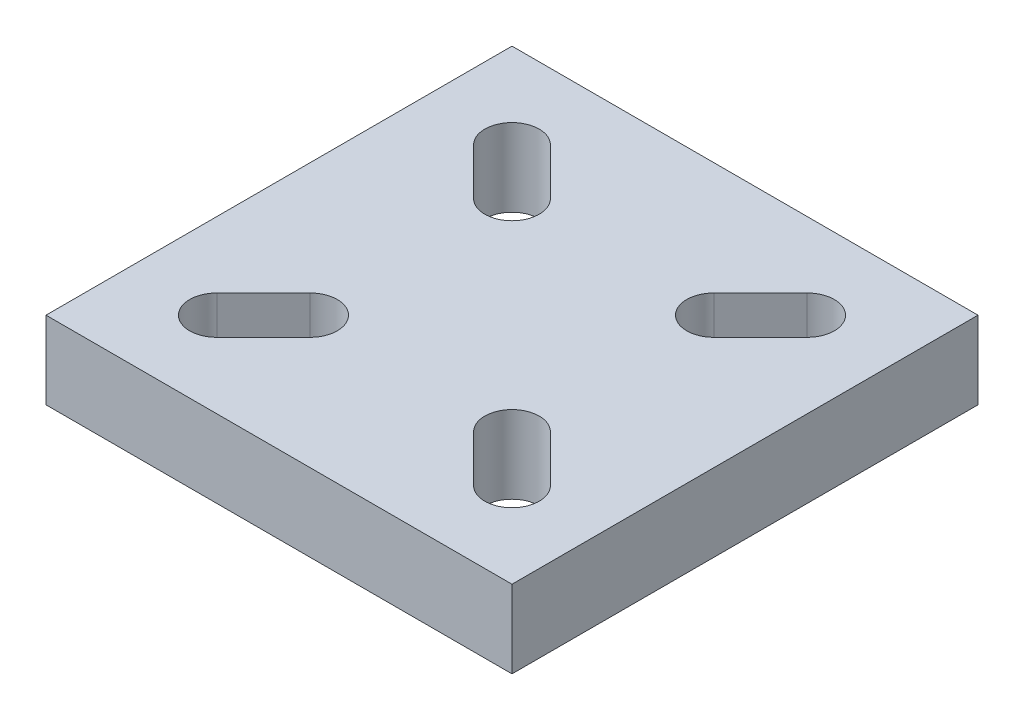
from build123d import *

# Parameters (mm, degrees)
SKETCH1_W           = 60
SKETCH1_H           = 60
BOSS_EXTRUDE1_DEPTH = 10
CUT_EXTRUDE1_DEPTH  = 11


with BuildPart() as part:
    # Sketch1 → Boss-Extrude1 (new body)
    with BuildSketch(Plane(origin=(0, 0, 0), x_dir=(1, 0, 0), z_dir=(0, 1, 0))):
        Rectangle(SKETCH1_W, SKETCH1_H)
    extrude(amount=BOSS_EXTRUDE1_DEPTH)

    # Sketch4 → Cut-Extrude1 (cut, through all)
    with BuildSketch(Plane(origin=(0, 10, 0), x_dir=(1, 0, 0), z_dir=(0, 1, 0))):
        with BuildLine():
            Line((-16.525126266, 21.474873734), (-10.525126266, 15.474873734))
            ThreePointArc((-10.525126266, 15.474873734), (-10.525126266, 10.525126266), (-15.474873734, 10.525126266))
            Line((-15.474873734, 10.525126266), (-21.474873734, 16.525126266))
            ThreePointArc((-21.474873734, 16.525126266), (-21.474873734, 21.474873734), (-16.525126266, 21.474873734))
        make_face()
        with BuildLine():
            Line((21.474873734, 16.525126266), (15.474873734, 10.525126266))
            ThreePointArc((15.474873734, 10.525126266), (10.525126266, 10.525126266), (10.525126266, 15.474873734))
            Line((10.525126266, 15.474873734), (16.525126266, 21.474873734))
            ThreePointArc((16.525126266, 21.474873734), (21.474873734, 21.474873734), (21.474873734, 16.525126266))
        make_face()
        with BuildLine():
            Line((16.525126266, -21.474873734), (10.525126266, -15.474873734))
            ThreePointArc((10.525126266, -15.474873734), (10.525126266, -10.525126266), (15.474873734, -10.525126266))
            Line((15.474873734, -10.525126266), (21.474873734, -16.525126266))
            ThreePointArc((21.474873734, -16.525126266), (21.474873734, -21.474873734), (16.525126266, -21.474873734))
        make_face()
        with BuildLine():
            Line((-21.474873734, -16.525126266), (-15.474873734, -10.525126266))
            ThreePointArc((-15.474873734, -10.525126266), (-10.525126266, -10.525126266), (-10.525126266, -15.474873734))
            Line((-10.525126266, -15.474873734), (-16.525126266, -21.474873734))
            ThreePointArc((-16.525126266, -21.474873734), (-21.474873734, -21.474873734), (-21.474873734, -16.525126266))
        make_face()
    extrude(amount=-CUT_EXTRUDE1_DEPTH, mode=Mode.SUBTRACT)


solid = part.part
